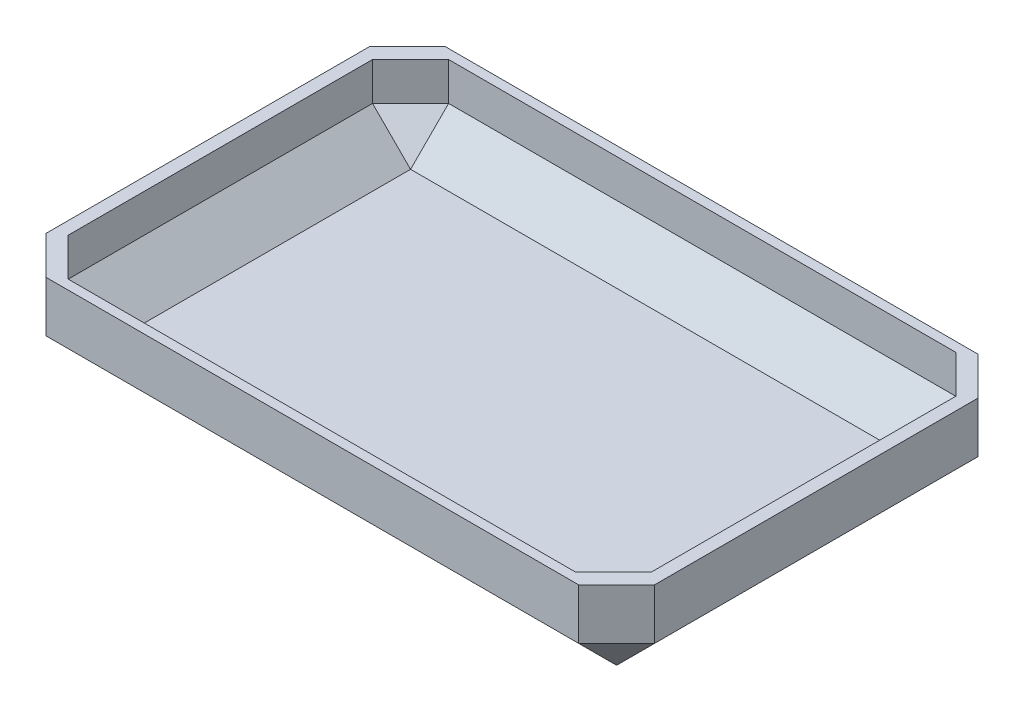
from build123d import *

# Parameters (mm, degrees)
SKETCH1_W           = 480
SKETCH1_H           = 315
BOSS_EXTRUDE1_DEPTH = 70
SKETCH3_W           = 460
SKETCH3_H           = 300
CUT_EXTRUDE1_DEPTH  = 60
CHAMFER1_SIZE       = 30


with BuildPart() as part:
    # Sketch1 → Boss-Extrude1 (new body)
    with BuildSketch(Plane(origin=(0, 0, 0), x_dir=(1, 0, 0), z_dir=(0, 1, 0))):
        Rectangle(SKETCH1_W, SKETCH1_H)
    extrude(amount=BOSS_EXTRUDE1_DEPTH)

    # Sketch3 → Cut-Extrude1 (cut)
    with BuildSketch(Plane(origin=(0, 70, 0), x_dir=(1, 0, 0), z_dir=(0, 1, 0))):
        Rectangle(SKETCH3_W, SKETCH3_H)
    extrude(amount=-CUT_EXTRUDE1_DEPTH, mode=Mode.SUBTRACT)

    # Chamfer1
    chamfer1_edges = [part.edges().sort_by_distance(p)[0] for p in [
        (230, 10, 0),
        (230, 40, -150),
        (0, 10, 150),
        (230, 40, 150),
        (-230, 10, 0),
        (-230, 40, 150),
        (0, 10, -150),
        (-230, 40, -150),
        (0, 0, -157.5),
        (240, 0, 0),
        (0, 0, 157.5),
        (-240, 0, 0),
        (-240, 35, -157.5),
        (240, 35, -157.5),
        (240, 35, 157.5),
        (-240, 35, 157.5),
    ]]
    chamfer(chamfer1_edges, length=CHAMFER1_SIZE)


solid = part.part
